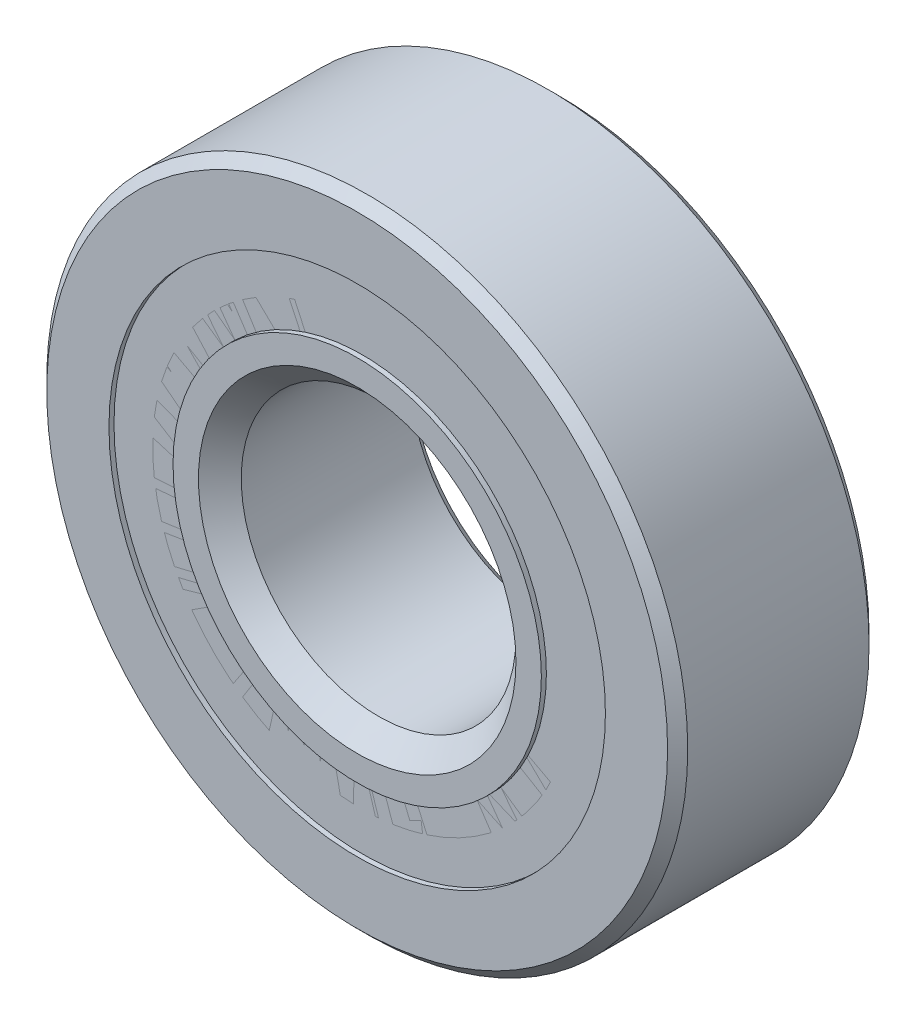
from build123d import *

# Parameters (mm, degrees)
CIRPATTERN1_COUNT = 8
SKETCH5_W         = 2.562629306
SKETCH5_H         = 3.498010256


with BuildPart() as part:
    # Sketch1 → Revolve1 (revolve)
    with BuildSketch(Plane(origin=(0, 0, 0), x_dir=(0, 0, -1), z_dir=(1, 0, 0))):
        with BuildLine():
            Line((4.95, 17.5), (-4.95, 17.5))
            Line((-4.95, 17.5), (-5.5, 16.95))
            Line((-5.5, 16.95), (-5.5, 13.554945055))
            Line((-5.5, 13.554945055), (-2.444444444, 13.554945055))
            ThreePointArc((-2.444444444, 13.554945055), (0, 15.162370694), (2.444444444, 13.554945055))
            Line((2.444444444, 13.554945055), (5.5, 13.554945055))
            Line((5.5, 13.554945055), (5.5, 16.95))
            Line((5.5, 16.95), (4.95, 17.5))
        make_face()
    revolve(axis=Axis((0, 0, 5.5), (0, 0, -1)))


with BuildPart() as body_2:
    # Sketch2 → Revolve2 (revolve)
    with BuildSketch(Plane(origin=(0, 0, 0), x_dir=(0, 0, -1), z_dir=(1, 0, 0))):
        with BuildLine():
            Line((-5.225, 11.445054945), (-2.444444444, 11.445054945))
            ThreePointArc((-2.444444444, 11.445054945), (-1.462799185, 10.275491907), (0, 9.837629306))
            Line((0, 9.837629306), (0, 8.668814653))
            Line((0, 8.668814653), (-4.111879854, 8.668814653))
            Line((-4.111879854, 8.668814653), (-5.225, 9.781934799))
            Line((-5.225, 9.781934799), (-5.225, 11.445054945))
        make_face()
    revolve(axis=Axis((0, 0, 5.5), (0, 0, -1)))


with BuildPart() as body_3:
    # Sketch3 → Revolve3 (revolve)
    with BuildSketch(Plane(origin=(0, 0, 0), x_dir=(0, 0, -1), z_dir=(1, 0, 0))):
        with BuildLine():
            Line((-5.225, 9.781934799), (-4.111879854, 8.668814653))
            Line((-4.111879854, 8.668814653), (0, 8.668814653))
            Line((0, 8.668814653), (0, 9.837629306))
            ThreePointArc((0, 9.837629306), (1.462799185, 10.275491907), (2.444444444, 11.445054945))
            Line((2.444444444, 11.445054945), (5.5, 11.445054945))
            Line((5.5, 11.445054945), (5.5, 8.05))
            Line((5.5, 8.05), (4.95, 7.5))
            Line((4.95, 7.5), (-4.331185347, 7.5))
            Line((-4.331185347, 7.5), (-5.5, 8.668814653))
            Line((-5.5, 8.668814653), (-5.5, 10.056934799))
            Line((-5.5, 10.056934799), (-5.225, 10.056934799))
            Line((-5.225, 10.056934799), (-5.225, 9.781934799))
        make_face()
    revolve(axis=Axis((0, 0, 5.5), (0, 0, -1)))


with BuildPart() as body_4:
    # Sketch4 → Revolve4 (revolve)
    with BuildSketch(Plane(origin=(0, 0, 0), x_dir=(0, 0, -1), z_dir=(1, 0, 0))):
        with BuildLine():
            Line((-2.662370694, 12.5), (2.662370694, 12.5))
            ThreePointArc((2.662370694, 12.5), (0, 15.162370694), (-2.662370694, 12.5))
        make_face()
    revolve(axis=Axis((0, 12.5, 2.662370694), (0, 0, -1)))


with BuildPart() as cirpattern1_1:
    # CirPattern1: pattern copy
    add(body_4.part.rotate(Axis((0, 0, -5.5), (0, 0, 1)), 1 * 360 / CIRPATTERN1_COUNT))


with BuildPart() as cirpattern1_2:
    # CirPattern1: pattern copy
    add(body_4.part.rotate(Axis((0, 0, -5.5), (0, 0, 1)), 2 * 360 / CIRPATTERN1_COUNT))


with BuildPart() as cirpattern1_3:
    # CirPattern1: pattern copy
    add(body_4.part.rotate(Axis((0, 0, -5.5), (0, 0, 1)), 3 * 360 / CIRPATTERN1_COUNT))


with BuildPart() as cirpattern1_4:
    # CirPattern1: pattern copy
    add(body_4.part.rotate(Axis((0, 0, -5.5), (0, 0, 1)), 4 * 360 / CIRPATTERN1_COUNT))


with BuildPart() as cirpattern1_5:
    # CirPattern1: pattern copy
    add(body_4.part.rotate(Axis((0, 0, -5.5), (0, 0, 1)), 5 * 360 / CIRPATTERN1_COUNT))


with BuildPart() as cirpattern1_6:
    # CirPattern1: pattern copy
    add(body_4.part.rotate(Axis((0, 0, -5.5), (0, 0, 1)), 6 * 360 / CIRPATTERN1_COUNT))


with BuildPart() as cirpattern1_7:
    # CirPattern1: pattern copy
    add(body_4.part.rotate(Axis((0, 0, -5.5), (0, 0, 1)), 7 * 360 / CIRPATTERN1_COUNT))


with BuildPart() as body_12:
    # Sketch5 → Revolve5 (revolve)
    with BuildSketch(Plane(origin=(0, 0, 0), x_dir=(0, 0, -1), z_dir=(1, 0, 0))):
        with Locations((-3.943685347, 11.805939927)):
            Rectangle(SKETCH5_W, SKETCH5_H)
        with Locations((3.943685347, 11.805939927)):
            Rectangle(SKETCH5_W, SKETCH5_H)
    revolve(axis=Axis((0, 0, 5.5), (0, 0, -1)))


solid = Compound([part.part, body_2.part, body_3.part, body_4.part, cirpattern1_1.part, cirpattern1_2.part, cirpattern1_3.part, cirpattern1_4.part, cirpattern1_5.part, cirpattern1_6.part, cirpattern1_7.part, body_12.part])
